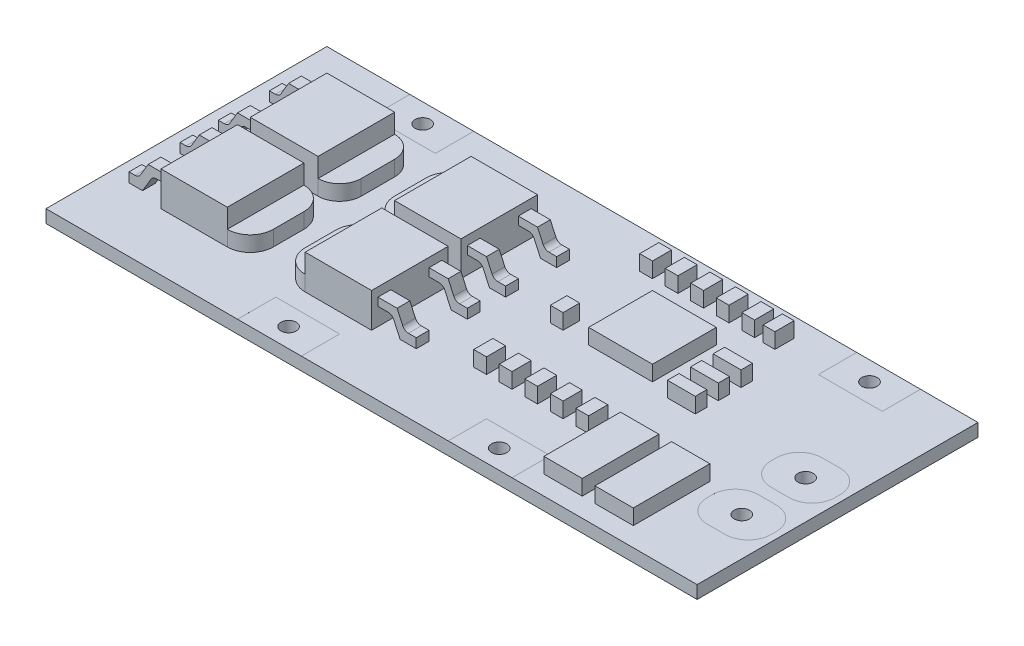
from build123d import *

# Parameters (mm, degrees)
SKETCH1_W                = 51
SKETCH1_H                = 22
SKETCH1_R                = 0.6
BOSS_EXTRUDE1_DEPTH      = 1
BOSS_EXTRUDE1_DEPTH_BACK = 0.01
SKETCH2_W                = 5
SKETCH2_H                = 3
CUT_EXTRUDE1_DEPTH       = 0.0001
SKETCH3_W                = 5
SKETCH3_H                = 3
CUT_EXTRUDE2_DEPTH       = 0.0001
SKETCH4_W                = 0.961538462
SKETCH4_H                = 0.256410257
BOSS_EXTRUDE2_DEPTH      = 0.0001
SKETCH5_W                = 3
SKETCH5_H                = 6
SKETCH5_W_2              = 5
SKETCH5_H_2              = 5
SKETCH5_W_3              = 1
SKETCH5_H_3              = 1.5
SKETCH5_W_4              = 0.919535101
SKETCH5_H_4              = 1.3
SKETCH5_W_5              = 2.183483736
SKETCH5_H_5              = 0.905155141
SKETCH5_H_6              = 0.884985371
SKETCH5_H_7              = 0.897685774
BOSS_EXTRUDE3_DEPTH      = 1.2
SKETCH6_W                = 5.2
SKETCH6_H                = 6
SKETCH6_W_2              = 5.307944278
BOSS_EXTRUDE4_DEPTH      = 1.5
SKETCH7_W                = 3
SKETCH7_H                = 1
BOSS_EXTRUDE5_DEPTH      = 2
CUT_EXTRUDE5_DEPTH       = 18


with BuildPart() as part:
    # Sketch1 → Boss-Extrude1 (new body, two sides)
    with BuildSketch(Plane(origin=(0, 0, 0), x_dir=(1, 0, 0), z_dir=(0, 1, 0))) as boss_extrude1_sk:
        Rectangle(SKETCH1_W, SKETCH1_H)
        with Locations((22.5, 0.5)):
            Circle(SKETCH1_R, mode=Mode.SUBTRACT)
        with Locations((22.5, -4.5)):
            Circle(SKETCH1_R, mode=Mode.SUBTRACT)
        with Locations((18.5, 9.5)):
            Circle(SKETCH1_R, mode=Mode.SUBTRACT)
        with Locations((-16.5, 9.5)):
            Circle(SKETCH1_R, mode=Mode.SUBTRACT)
        with Locations((8.5, -9.5)):
            Circle(SKETCH1_R, mode=Mode.SUBTRACT)
        with Locations((-8, -9.5)):
            Circle(SKETCH1_R, mode=Mode.SUBTRACT)
    extrude(amount=BOSS_EXTRUDE1_DEPTH)
    extrude(boss_extrude1_sk.sketch, amount=-BOSS_EXTRUDE1_DEPTH_BACK)

    # Sketch2 → Cut-Extrude1 (cut)
    with BuildSketch(Plane(origin=(0, 1, 0), x_dir=(1, 0, 0), z_dir=(0, 1, 0))):
        with Locations((-16.5, 9.5)):
            Rectangle(SKETCH2_W, SKETCH2_H)
        with Locations((18.5, 9.5)):
            Rectangle(SKETCH2_W, SKETCH2_H)
        with Locations((-8, -9.5)):
            Rectangle(SKETCH2_W, SKETCH2_H)
        with Locations((8.5, -9.5)):
            Rectangle(SKETCH2_W, SKETCH2_H)
        with BuildLine():
            Line((21.8, 2.5), (23.2, 2.5))
            ThreePointArc((23.2, 2.5), (24.472792206, 1.972792206), (25, 0.7))
            Line((25, 0.7), (25, 0.3))
            ThreePointArc((25, 0.3), (24.472792206, -0.972792206), (23.2, -1.5))
            Line((23.2, -1.5), (21.8, -1.5))
            ThreePointArc((21.8, -1.5), (20.527207794, -0.972792206), (20, 0.3))
            Line((20, 0.3), (20, 0.7))
            ThreePointArc((20, 0.7), (20.527207794, 1.972792206), (21.8, 2.5))
        make_face()
        with BuildLine():
            Line((21.8, -2.5), (23.2, -2.5))
            ThreePointArc((23.2, -2.5), (24.472792206, -3.027207794), (25, -4.3))
            Line((25, -4.3), (25, -4.7))
            ThreePointArc((25, -4.7), (24.472792206, -5.972792206), (23.2, -6.5))
            Line((23.2, -6.5), (21.8, -6.5))
            ThreePointArc((21.8, -6.5), (20.527207794, -5.972792206), (20, -4.7))
            Line((20, -4.7), (20, -4.3))
            ThreePointArc((20, -4.3), (20.527207794, -3.027207794), (21.8, -2.5))
        make_face()
    extrude(amount=-CUT_EXTRUDE1_DEPTH, mode=Mode.SUBTRACT)

    # Sketch3 → Cut-Extrude2 (cut)
    with BuildSketch(Plane.XZ.offset(0.01)):
        with Locations((18.5, -9.5)):
            Rectangle(SKETCH3_W, SKETCH3_H)
        with Locations((-16.5, -9.5)):
            Rectangle(SKETCH3_W, SKETCH3_H)
        with Locations((-8, 9.5)):
            Rectangle(SKETCH3_W, SKETCH3_H)
        with Locations((8.5, 9.5)):
            Rectangle(SKETCH3_W, SKETCH3_H)
        with BuildLine():
            Line((23.2, 2.5), (21.8, 2.5))
            ThreePointArc((21.8, 2.5), (20.527207794, 3.027207794), (20, 4.3))
            Line((20, 4.3), (20, 4.7))
            ThreePointArc((20, 4.7), (20.527207794, 5.972792206), (21.8, 6.5))
            Line((21.8, 6.5), (23.2, 6.5))
            ThreePointArc((23.2, 6.5), (24.472792206, 5.972792206), (25, 4.7))
            Line((25, 4.7), (25, 4.3))
            ThreePointArc((25, 4.3), (24.472792206, 3.027207794), (23.2, 2.5))
        make_face()
        with BuildLine():
            Line((23.2, -2.5), (21.8, -2.5))
            ThreePointArc((21.8, -2.5), (20.527207794, -1.972792206), (20, -0.7))
            Line((20, -0.7), (20, -0.3))
            ThreePointArc((20, -0.3), (20.527207794, 0.972792206), (21.8, 1.5))
            Line((21.8, 1.5), (23.2, 1.5))
            ThreePointArc((23.2, 1.5), (24.472792206, 0.972792206), (25, -0.3))
            Line((25, -0.3), (25, -0.7))
            ThreePointArc((25, -0.7), (24.472792206, -1.972792206), (23.2, -2.5))
        make_face()
    extrude(amount=-CUT_EXTRUDE2_DEPTH, mode=Mode.SUBTRACT)

    # Sketch4 → Boss-Extrude2 (add)
    with BuildSketch(Plane.XZ.offset(0.01)):
        Polygon((7.251426229, 1.791905181), (6.992511966, 1.791905181), (6.33796469, 0.769268963), (5.683417415, 1.791905181), (5.424503152, 1.791905181), (6.208257158, 0.566945245), (5.39245187, -0.708094819), (5.651366133, -0.708094819), (6.33796469, 0.364621527), (7.024563248, -0.708094819), (7.283477511, -0.708094819), (6.467171421, 0.566945245), align=None)
        Polygon((4.959759562, 1.791905181), (4.735400588, 1.791905181), (4.735400588, 0.766264155), (3.453349306, 0.766264155), (3.453349306, 1.791905181), (3.228990331, 1.791905181), (3.228990331, -0.708094819), (3.453349306, -0.708094819), (3.453349306, 0.509853899), (4.735400588, 0.509853899), (4.735400588, -0.708094819), (4.959759562, -0.708094819), align=None)
        with Locations((2.331554434, 0.253443643)):
            Rectangle(SKETCH4_W, SKETCH4_H)
        with BuildLine():
            Line((1.33796469, 1.214982104), (1.562323665, 1.214982104))
            add(Edge.make_bspline(
                [(1.562323665, 1.214982104), (1.556245414, 1.240148164), (1.544362932, 1.289345753), (1.519578951, 1.359636654), (1.492579483, 1.426153455), (1.460158694, 1.48765065), (1.424795298, 1.545364152), (1.384279068, 1.597984955), (1.340479266, 1.646851359), (1.292032874, 1.690217957), (1.241226687, 1.729487764), (1.187344816, 1.762969948), (1.13147132, 1.791772914), (1.073219082, 1.815501651), (1.012414674, 1.833377025), (0.9496078, 1.846346172), (0.884633872, 1.854768396), (0.84052845, 1.85559037), (0.81813296, 1.856007745)],
                knots=[0, 0, 0, 0, 7.7618e-05, 0.000151736, 0.000223351, 0.000292789, 0.000360048, 0.000426155, 0.000491745, 0.000556627, 0.000620933, 0.000684157, 0.000746647, 0.000809327, 0.000872549, 0.000936489, 0.001001588, 0.001068742, 0.001068742, 0.001068742, 0.001068742], degree=3))
            add(Edge.make_bspline(
                [(0.81813296, 1.856007745), (0.78550243, 1.855022581), (0.720953136, 1.853073741), (0.626122388, 1.835277715), (0.53467466, 1.807116906), (0.447610912, 1.768207101), (0.366740603, 1.720216163), (0.294786184, 1.663098494), (0.232722962, 1.597956136), (0.180655549, 1.526004304), (0.139887693, 1.449107512), (0.109825997, 1.369964542), (0.091524797, 1.288763134), (0.08915297, 1.233936506), (0.08796469, 1.206468482)],
                knots=[0, 0, 0, 0, 9.7812e-05, 0.000193489, 0.000288374, 0.000384325, 0.000478887, 0.000569769, 0.000659033, 0.00074799, 0.000835365, 0.000919359, 0.001001382, 0.001083733, 0.001083733, 0.001083733, 0.001083733], degree=3))
            add(Edge.make_bspline(
                [(0.08796469, 1.206468482), (0.088795827, 1.180035058), (0.090422232, 1.128308947), (0.104232022, 1.052793592), (0.127472209, 0.98162102), (0.159664897, 0.914491619), (0.201337433, 0.851831019), (0.251817931, 0.79349824), (0.311462689, 0.739234556), (0.35666193, 0.708149218), (0.379931838, 0.692145566)],
                knots=[0, 0, 0, 0, 7.9255e-05, 0.000155089, 0.000229365, 0.000303282, 0.000377732, 0.000454431, 0.000534203, 0.000618852, 0.000618852, 0.000618852, 0.000618852], degree=3))
            add(Edge.make_bspline(
                [(0.379931838, 0.692145566), (0.353337727, 0.679304015), (0.300647103, 0.653861188), (0.228825296, 0.603964218), (0.163626814, 0.546352541), (0.127267014, 0.501393504), (0.108998344, 0.47880422)],
                knots=[0, 0, 0, 0, 8.8473e-05, 0.000175291, 0.000261465, 0.000348485, 0.000348485, 0.000348485, 0.000348485], degree=3))
            add(Edge.make_bspline(
                [(0.108998344, 0.47880422), (0.096968814, 0.462334397), (0.073106745, 0.429664457), (0.043652793, 0.377138438), (0.016931997, 0.324030231), (-0.003889589, 0.26891637), (-0.020013779, 0.212435646), (-0.031539516, 0.154491077), (-0.038699617, 0.095035347), (-0.039725011, 0.054812147), (-0.040240438, 0.034593482)],
                knots=[0, 0, 0, 0, 6.1131e-05, 0.00012126, 0.000180389, 0.000239356, 0.00029769, 0.000356423, 0.000416429, 0.000477078, 0.000477078, 0.000477078, 0.000477078], degree=3))
            add(Edge.make_bspline(
                [(-0.040240438, 0.034593482), (-0.038958643, -0.000413461), (-0.036401084, -0.070262606), (-0.013541031, -0.173458835), (0.021896998, -0.274334194), (0.072223381, -0.370816222), (0.133557316, -0.461087923), (0.206526833, -0.541856715), (0.290302839, -0.61128429), (0.383735446, -0.669291595), (0.484961966, -0.71566154), (0.593230246, -0.747845427), (0.706980284, -0.768806856), (0.784985497, -0.771054619), (0.824643376, -0.772197383)],
                knots=[0, 0, 0, 0, 0.000104902, 0.00020931, 0.000315595, 0.000424898, 0.000534775, 0.000642204, 0.000750312, 0.000860092, 0.000971252, 0.001083258, 0.001198198, 0.001317066, 0.001317066, 0.001317066, 0.001317066], degree=3))
            add(Edge.make_bspline(
                [(0.824643376, -0.772197383), (0.851371448, -0.771577231), (0.90396338, -0.770356978), (0.981280165, -0.76201512), (1.055081378, -0.746779402), (1.125466805, -0.726277041), (1.192498974, -0.700282939), (1.255973335, -0.667912441), (1.316280402, -0.629832796), (1.372851081, -0.585594519), (1.42567863, -0.536107848), (1.473359147, -0.48049427), (1.516687571, -0.419781838), (1.554503741, -0.353265369), (1.588530136, -0.281804471), (1.616516533, -0.204484115), (1.641149082, -0.121995528), (1.652601557, -0.064511428), (1.658477511, -0.035017896)],
                knots=[0, 0, 0, 0, 8.0185e-05, 0.000157776, 0.000232912, 0.000305969, 0.000377485, 0.000448259, 0.000519394, 0.000591121, 0.000663393, 0.000736181, 0.000810525, 0.000886804, 0.000965437, 0.001047673, 0.00113325, 0.001223422, 0.001223422, 0.001223422, 0.001223422], degree=3))
            Line((1.658477511, -0.035017896), (1.434118536, -0.035017896))
            add(Edge.make_bspline(
                [(1.434118536, -0.035017896), (1.428273328, -0.054267191), (1.416903891, -0.091708742), (1.397550821, -0.145594675), (1.375502055, -0.194993284), (1.351848799, -0.240266943), (1.327007052, -0.281861516), (1.299210676, -0.318677137), (1.27051843, -0.352330853), (1.24889032, -0.37129129), (1.238305235, -0.38057078)],
                knots=[0, 0, 0, 0, 6.0348e-05, 0.000117382, 0.000171638, 0.000222486, 0.000270584, 0.000316758, 0.00036076, 0.000402938, 0.000402938, 0.000402938, 0.000402938], degree=3))
            add(Edge.make_bspline(
                [(1.238305235, -0.38057078), (1.224307681, -0.391362448), (1.196355778, -0.41291247), (1.150807042, -0.440413634), (1.102903552, -0.464242937), (1.051607356, -0.482445577), (0.998025377, -0.497858192), (0.941291545, -0.507944277), (0.88190639, -0.514864399), (0.841357987, -0.515475065), (0.820636966, -0.515787127)],
                knots=[0, 0, 0, 0, 5.2986e-05, 0.000105808, 0.000159337, 0.000213205, 0.000268857, 0.000326417, 0.000385869, 0.000448001, 0.000448001, 0.000448001, 0.000448001], degree=3))
            add(Edge.make_bspline(
                [(0.820636966, -0.515787127), (0.797241607, -0.515347194), (0.751494002, -0.514486945), (0.684740531, -0.506575725), (0.621235211, -0.495054002), (0.561683122, -0.477259014), (0.505304188, -0.455272691), (0.452888724, -0.427666688), (0.403748648, -0.395277601), (0.358513358, -0.358463916), (0.317837996, -0.318162848), (0.282024058, -0.276010654), (0.251577871, -0.232185062), (0.227018172, -0.186443547), (0.207624922, -0.138975526), (0.194422636, -0.089647791), (0.185242982, -0.038864029), (0.184495402, -0.004343337), (0.184118536, 0.013059027)],
                knots=[0, 0, 0, 0, 7.0157e-05, 0.000137186, 0.000201421, 0.000263541, 0.000323338, 0.000382699, 0.000440898, 0.000499637, 0.000557359, 0.000612441, 0.000665367, 0.000717127, 0.000767903, 0.00081881, 0.000870103, 0.000922246, 0.000922246, 0.000922246, 0.000922246], degree=3))
            add(Edge.make_bspline(
                [(0.184118536, 0.013059027), (0.185211609, 0.036352841), (0.187392315, 0.082824561), (0.2040413, 0.151194257), (0.231426203, 0.217068123), (0.269763711, 0.279322259), (0.316432089, 0.337019331), (0.370978451, 0.388498961), (0.433855757, 0.430977598), (0.491727092, 0.460326638), (0.542987918, 0.48035312), (0.58685605, 0.493692381), (0.635967909, 0.504987849), (0.689729587, 0.515496614), (0.74854617, 0.524440435), (0.812353626, 0.531898874), (0.881164884, 0.537866761), (0.928801431, 0.540531829), (0.953349306, 0.541905181)],
                knots=[0, 0, 0, 0, 6.9829e-05, 0.000139311, 0.000209808, 0.000283071, 0.000357843, 0.000431895, 0.000507184, 0.000584677, 0.000626062, 0.000672161, 0.000722085, 0.000777185, 0.000836468, 0.000900512, 0.000969883, 0.001043639, 0.001043639, 0.001043639, 0.001043639], degree=3))
            Line((0.953349306, 0.541905181), (0.953349306, 0.798315437))
            add(Edge.make_bspline(
                [(0.953349306, 0.798315437), (0.922419902, 0.798840297), (0.861836797, 0.799868369), (0.773340865, 0.812302662), (0.688717071, 0.82950311), (0.609840826, 0.855849676), (0.537948888, 0.886449888), (0.475577744, 0.922058609), (0.42360121, 0.961640573), (0.382271873, 1.005806723), (0.351179567, 1.053174614), (0.32844614, 1.102543655), (0.315017336, 1.154346556), (0.313224717, 1.18969989), (0.312323665, 1.207470085)],
                knots=[0, 0, 0, 0, 9.2715e-05, 0.000181605, 0.00026765, 0.000351427, 0.000430601, 0.000501726, 0.000566337, 0.000625867, 0.00068226, 0.000735602, 0.000788317, 0.000841593, 0.000841593, 0.000841593, 0.000841593], degree=3))
            add(Edge.make_bspline(
                [(0.312323665, 1.207470085), (0.312619673, 1.220525617), (0.313208566, 1.246498979), (0.320635193, 1.284445457), (0.331795222, 1.321231847), (0.347137886, 1.356701711), (0.367673742, 1.39060905), (0.392249447, 1.423242942), (0.421512376, 1.45441707), (0.455044838, 1.483474441), (0.49105327, 1.511166753), (0.530517395, 1.534676494), (0.572247306, 1.55478011), (0.616289202, 1.571358325), (0.662786009, 1.583829246), (0.711519265, 1.592783418), (0.762581896, 1.598381743), (0.797418847, 1.599187754), (0.815128152, 1.599597489)],
                knots=[0, 0, 0, 0, 3.9114e-05, 7.7815e-05, 0.000115518, 0.000154317, 0.000193395, 0.000234161, 0.000276679, 0.000321388, 0.000367161, 0.000412767, 0.000458909, 0.000505976, 0.000553721, 0.000603128, 0.000654505, 0.000707628, 0.000707628, 0.000707628, 0.000707628], degree=3))
            add(Edge.make_bspline(
                [(0.815128152, 1.599597489), (0.843593629, 1.598603659), (0.899193326, 1.596662478), (0.979346839, 1.579660325), (1.053860649, 1.552533123), (1.110816839, 1.520152394), (1.15287582, 1.488187799), (1.182930776, 1.460271809), (1.212445427, 1.429248363), (1.239478053, 1.393206666), (1.266816608, 1.354587531), (1.29170558, 1.311427758), (1.315891075, 1.264853191), (1.330464324, 1.231927738), (1.33796469, 1.214982104)],
                knots=[0, 0, 0, 0, 8.5314e-05, 0.000166639, 0.000244596, 0.000322429, 0.000362093, 0.000402856, 0.000445374, 0.000490351, 0.000537861, 0.000587248, 0.00063966, 0.00069524, 0.00069524, 0.00069524, 0.00069524], degree=3))
        make_face()
        with BuildLine():
            Line((-0.23254813, -0.225823184), (-0.443886271, -0.09912046))
            add(Edge.make_bspline(
                [(-0.443886271, -0.09912046), (-0.463542155, -0.132023592), (-0.50120207, -0.195064723), (-0.564024469, -0.280249038), (-0.629119406, -0.352650579), (-0.69696893, -0.411848155), (-0.767158893, -0.458454503), (-0.840147502, -0.491456097), (-0.915688796, -0.512038937), (-0.967098668, -0.514538999), (-0.992764476, -0.515787127)],
                knots=[0, 0, 0, 0, 0.000114929, 0.0002202, 0.000316984, 0.00040645, 0.000489652, 0.000568774, 0.000645907, 0.000722806, 0.000722806, 0.000722806, 0.000722806], degree=3))
            add(Edge.make_bspline(
                [(-0.992764476, -0.515787127), (-1.014683662, -0.515176646), (-1.0581385, -0.513966368), (-1.122111531, -0.502337223), (-1.18424139, -0.484471417), (-1.24324756, -0.458885037), (-1.298315856, -0.427928976), (-1.346606352, -0.390538849), (-1.388353576, -0.348677274), (-1.422502944, -0.301975377), (-1.448702969, -0.251748843), (-1.46884016, -0.200194592), (-1.480015213, -0.146502757), (-1.481698608, -0.110352427), (-1.48254813, -0.092109242)],
                knots=[0, 0, 0, 0, 6.5699e-05, 0.000130248, 0.00019443, 0.000259268, 0.000322751, 0.000383454, 0.000441885, 0.000499581, 0.00055626, 0.000611417, 0.000665143, 0.000719877, 0.000719877, 0.000719877, 0.000719877], degree=3))
            add(Edge.make_bspline(
                [(-1.48254813, -0.092109242), (-1.481495051, -0.071294349), (-1.479354295, -0.028980714), (-1.461260381, 0.033447609), (-1.432796633, 0.095228016), (-1.406537602, 0.133443206), (-1.392904701, 0.153283386)],
                knots=[0, 0, 0, 0, 6.2343e-05, 0.000126735, 0.000193507, 0.000265603, 0.000265603, 0.000265603, 0.000265603], degree=3))
            add(Edge.make_bspline(
                [(-1.392904701, 0.153283386), (-1.381711405, 0.167602546), (-1.35821248, 0.197663831), (-1.317814257, 0.242410427), (-1.27040989, 0.288566441), (-1.217621636, 0.337894339), (-1.157526573, 0.388099908), (-1.09200692, 0.441577249), (-1.019389877, 0.496292661), (-0.968461666, 0.532987351), (-0.942183547, 0.551921207)],
                knots=[0, 0, 0, 0, 5.4514e-05, 0.000114445, 0.000180666, 0.000252962, 0.000331129, 0.000415521, 0.000506668, 0.000603835, 0.000603835, 0.000603835, 0.000603835], degree=3))
            add(Edge.make_bspline(
                [(-0.942183547, 0.551921207), (-0.915880692, 0.570655912), (-0.865591638, 0.606475242), (-0.795264079, 0.659635445), (-0.732375177, 0.708238209), (-0.677204451, 0.752741075), (-0.629776167, 0.793150078), (-0.589716588, 0.829077178), (-0.55804619, 0.861494007), (-0.540435061, 0.882523537), (-0.532528098, 0.891965277)],
                knots=[0, 0, 0, 0, 9.6874e-05, 0.000185215, 0.000264453, 0.000335314, 0.000397836, 0.000451365, 0.000496698, 0.000533635, 0.000533635, 0.000533635, 0.000533635], degree=3))
            add(Edge.make_bspline(
                [(-0.532528098, 0.891965277), (-0.52147628, 0.906680304), (-0.499741397, 0.935619378), (-0.471051393, 0.980851419), (-0.446666277, 1.027153751), (-0.427550325, 1.074650797), (-0.411453026, 1.122675747), (-0.400625932, 1.171855208), (-0.393846363, 1.221968507), (-0.393152087, 1.255692436), (-0.39280454, 1.272574252)],
                knots=[0, 0, 0, 0, 5.5193e-05, 0.000108544, 0.000160512, 0.000211941, 0.000261986, 0.000312286, 0.000362787, 0.000413408, 0.000413408, 0.000413408, 0.000413408], degree=3))
            add(Edge.make_bspline(
                [(-0.39280454, 1.272574252), (-0.393736833, 1.299024091), (-0.39558149, 1.351358422), (-0.411181859, 1.427809015), (-0.435805355, 1.500799313), (-0.470301703, 1.569606694), (-0.514771241, 1.632439538), (-0.566232651, 1.6900206), (-0.62752657, 1.73842673), (-0.694778444, 1.780721057), (-0.768390138, 1.81382529), (-0.845526498, 1.838797418), (-0.926310121, 1.852946888), (-0.981026645, 1.854977435), (-1.008790117, 1.856007745)],
                knots=[0, 0, 0, 0, 7.9285e-05, 0.000156875, 0.000233051, 0.000309872, 0.000386839, 0.000463411, 0.000540685, 0.000620313, 0.000701216, 0.00078215, 0.000863002, 0.000946286, 0.000946286, 0.000946286, 0.000946286], degree=3))
            add(Edge.make_bspline(
                [(-1.008790117, 1.856007745), (-1.038250189, 1.854991637), (-1.096836869, 1.852970922), (-1.18301488, 1.835401257), (-1.26598682, 1.806329348), (-1.332732009, 1.77333745), (-1.384969696, 1.740386438), (-1.424807362, 1.710372278), (-1.46517697, 1.675818629), (-1.506404152, 1.636633453), (-1.547790337, 1.592457203), (-1.589949946, 1.543592425), (-1.632981567, 1.490337742), (-1.660664324, 1.452320242), (-1.674855822, 1.432830662)],
                knots=[0, 0, 0, 0, 8.8313e-05, 0.000175626, 0.000262577, 0.000351492, 0.000398313, 0.000447692, 0.00050098, 0.000557657, 0.000618237, 0.000682498, 0.000751247, 0.000823563, 0.000823563, 0.000823563, 0.000823563], degree=3))
            Line((-1.674855822, 1.432830662), (-1.472031303, 1.279084668))
            add(Edge.make_bspline(
                [(-1.472031303, 1.279084668), (-1.459784209, 1.294862304), (-1.436199168, 1.325246342), (-1.400392392, 1.367797282), (-1.366643357, 1.406666196), (-1.333393072, 1.440427002), (-1.302397621, 1.470928525), (-1.272314019, 1.497042637), (-1.243575197, 1.519025206), (-1.207348832, 1.542484891), (-1.161836176, 1.565739537), (-1.104704364, 1.58541745), (-1.044999882, 1.597242494), (-1.00433586, 1.598805985), (-0.983750053, 1.599597489)],
                knots=[0, 0, 0, 0, 5.9912e-05, 0.000115377, 0.000166823, 0.000214281, 0.000257489, 0.000297251, 0.00033371, 0.000365937, 0.000426633, 0.0004865, 0.000546706, 0.000608435, 0.000608435, 0.000608435, 0.000608435], degree=3))
            add(Edge.make_bspline(
                [(-0.983750053, 1.599597489), (-0.957923966, 1.598731989), (-0.908120789, 1.597062954), (-0.837413478, 1.578834393), (-0.77377496, 1.550133064), (-0.719094556, 1.50990808), (-0.673568144, 1.462250228), (-0.640635673, 1.407408188), (-0.620814127, 1.346849329), (-0.618395356, 1.304605289), (-0.617163515, 1.283091078)],
                knots=[0, 0, 0, 0, 7.732e-05, 0.000149104, 0.00021745, 0.000285567, 0.000351467, 0.000413907, 0.00047599, 0.000540422, 0.000540422, 0.000540422, 0.000540422], degree=3))
            add(Edge.make_bspline(
                [(-0.617163515, 1.283091078), (-0.61744432, 1.269697165), (-0.618006388, 1.242887437), (-0.625845529, 1.203279279), (-0.635916479, 1.163771179), (-0.651875501, 1.124540763), (-0.673907861, 1.084901935), (-0.70284013, 1.044172122), (-0.73927821, 1.00199233), (-0.767190361, 0.974558492), (-0.781927137, 0.960074252)],
                knots=[0, 0, 0, 0, 4.0114e-05, 8.0294e-05, 0.000120747, 0.000162317, 0.000206922, 0.000256524, 0.00031193, 0.000373902, 0.000373902, 0.000373902, 0.000373902], degree=3))
            add(Edge.make_bspline(
                [(-0.781927137, 0.960074252), (-0.787399545, 0.955190662), (-0.800400736, 0.94358837), (-0.824169255, 0.924593884), (-0.855556968, 0.901163332), (-0.893744254, 0.872172392), (-0.939435227, 0.838542776), (-0.99263491, 0.800704482), (-1.05275029, 0.757429154), (-1.095408802, 0.727173768), (-1.117964797, 0.711176014)],
                knots=[0, 0, 0, 0, 2.2001e-05, 5.227e-05, 9.1232e-05, 0.00013951, 0.000196103, 0.000261422, 0.000335358, 0.000418317, 0.000418317, 0.000418317, 0.000418317], degree=3))
            add(Edge.make_bspline(
                [(-1.117964797, 0.711176014), (-1.145097592, 0.691432186), (-1.197636489, 0.653200999), (-1.272391904, 0.595761228), (-1.340173195, 0.53958425), (-1.401218341, 0.485028817), (-1.456130418, 0.43250875), (-1.504300219, 0.381392193), (-1.546218562, 0.332045355), (-1.591346575, 0.26877923), (-1.637459303, 0.191078455), (-1.67706038, 0.095879713), (-1.702030628, 0.000310913), (-1.705295996, -0.063922542), (-1.706907105, -0.095614851)],
                knots=[0, 0, 0, 0, 0.000100666, 0.000194926, 0.000282772, 0.000364703, 0.000440498, 0.000510646, 0.000575344, 0.000634551, 0.000743634, 0.000845566, 0.000943101, 0.001038091, 0.001038091, 0.001038091, 0.001038091], degree=3))
            add(Edge.make_bspline(
                [(-1.706907105, -0.095614851), (-1.70643772, -0.118027969), (-1.705508067, -0.162418957), (-1.6948217, -0.227601155), (-1.679164796, -0.290908919), (-1.655566772, -0.351559714), (-1.626764516, -0.410663116), (-1.590217196, -0.466668759), (-1.547854564, -0.520816186), (-1.499259018, -0.571661537), (-1.446083373, -0.618337391), (-1.389880734, -0.65985815), (-1.33055911, -0.694478381), (-1.268440313, -0.722728982), (-1.203510072, -0.744824352), (-1.135790227, -0.760833544), (-1.065169147, -0.770659052), (-1.017168803, -0.771678881), (-0.992764476, -0.772197383)],
                knots=[0, 0, 0, 0, 6.7175e-05, 0.000133045, 0.000197664, 0.000262492, 0.00032789, 0.00039457, 0.000462695, 0.000533896, 0.000605222, 0.000674738, 0.000743194, 0.000810877, 0.000879135, 0.000948616, 0.001019371, 0.00109255, 0.00109255, 0.00109255, 0.00109255], degree=3))
            add(Edge.make_bspline(
                [(-0.992764476, -0.772197383), (-0.973882088, -0.771832253), (-0.936355117, -0.771106592), (-0.880848344, -0.764691392), (-0.826462923, -0.755614889), (-0.773881293, -0.74120484), (-0.722425999, -0.723721284), (-0.672320832, -0.702193904), (-0.623541508, -0.676395903), (-0.575814663, -0.646899457), (-0.529261681, -0.612572496), (-0.484319204, -0.572591428), (-0.439512643, -0.528058924), (-0.396164502, -0.477765664), (-0.353397971, -0.422524177), (-0.31205625, -0.361817617), (-0.271283594, -0.29597665), (-0.245701117, -0.249644446), (-0.23254813, -0.225823184)],
                knots=[0, 0, 0, 0, 5.6626e-05, 0.000112539, 0.000167456, 0.000221878, 0.000275883, 0.000330397, 0.00038528, 0.000441284, 0.000498577, 0.00055855, 0.000621584, 0.000687964, 0.000757583, 0.000831066, 0.000908199, 0.000989822, 0.000989822, 0.000989822, 0.000989822], degree=3))
        make_face()
        with Locations((-2.476137874, 0.253443643)):
            Rectangle(SKETCH4_W, SKETCH4_H)
        with BuildLine():
            Line((-3.373573771, -0.708094819), (-3.373573771, 1.791905181))
            Line((-3.373573771, 1.791905181), (-3.878381464, 1.791905181))
            add(Edge.make_bspline(
                [(-3.878381464, 1.791905181), (-3.922287884, 1.79158906), (-4.007114859, 1.790978315), (-4.129695178, 1.787105892), (-4.243112152, 1.78025556), (-4.346992765, 1.770277327), (-4.441622202, 1.75802516), (-4.526735494, 1.742667728), (-4.602772739, 1.724533321), (-4.649536625, 1.709072285), (-4.671650694, 1.70176095)],
                knots=[0, 0, 0, 0, 0.000131719, 0.000254481, 0.000367879, 0.000472526, 0.000567506, 0.000654046, 0.000731904, 0.000801753, 0.000801753, 0.000801753, 0.000801753], degree=3))
            add(Edge.make_bspline(
                [(-4.671650694, 1.70176095), (-4.700575508, 1.690739018), (-4.757769217, 1.668945093), (-4.839202876, 1.62783345), (-4.915863849, 1.581252663), (-4.988163239, 1.529141332), (-5.054449543, 1.47002394), (-5.117312327, 1.406411736), (-5.174179986, 1.335991493), (-5.226257341, 1.260223645), (-5.273211383, 1.18000075), (-5.314025067, 1.095475673), (-5.347920777, 1.007077667), (-5.376058796, 0.915052561), (-5.398234837, 0.819198006), (-5.413364788, 0.719402387), (-5.423344067, 0.616060109), (-5.42434696, 0.545935492), (-5.424855822, 0.5103547)],
                knots=[0, 0, 0, 0, 9.2811e-05, 0.000183516, 0.000273184, 0.000361735, 0.000450446, 0.000539336, 0.000629753, 0.000721575, 0.00081494, 0.000908343, 0.001002834, 0.001098676, 0.001196834, 0.001297696, 0.001401299, 0.001508012, 0.001508012, 0.001508012, 0.001508012], degree=3))
            add(Edge.make_bspline(
                [(-5.424855822, 0.5103547), (-5.42440656, 0.479453816), (-5.423521241, 0.418560395), (-5.41557173, 0.328816898), (-5.404017216, 0.241735776), (-5.386128503, 0.157731704), (-5.364412422, 0.076068691), (-5.336580885, -0.002382912), (-5.304698388, -0.078342775), (-5.267519903, -0.15078383), (-5.226704628, -0.21941481), (-5.182903383, -0.284111616), (-5.136162886, -0.34395106), (-5.086037434, -0.399114354), (-5.03317478, -0.449518339), (-4.977228829, -0.495584064), (-4.918055222, -0.536410175), (-4.855918991, -0.573600966), (-4.78900747, -0.606044077), (-4.71605328, -0.633494084), (-4.636745296, -0.656241667), (-4.551278184, -0.675220878), (-4.459504271, -0.690276094), (-4.361333581, -0.700366374), (-4.256916946, -0.707189898), (-4.185217471, -0.707787322), (-4.148313355, -0.708094819)],
                knots=[0, 0, 0, 0, 9.2682e-05, 0.00018264, 0.000270108, 0.000356049, 0.000440118, 0.000523429, 0.000605562, 0.000687088, 0.000767479, 0.000844986, 0.000921325, 0.000995067, 0.001068392, 0.001140274, 0.001212236, 0.001283866, 0.001357332, 0.001434997, 0.001517409, 0.001604646, 0.001697516, 0.001796235, 0.001900605, 0.0020113, 0.0020113, 0.0020113, 0.0020113], degree=3))
            Line((-4.148313355, -0.708094819), (-3.373573771, -0.708094819))
        make_face()
        with BuildLine():
            Line((-3.597932746, -0.451684563), (-3.88489188, -0.451684563))
            add(Edge.make_bspline(
                [(-3.88489188, -0.451684563), (-3.926126431, -0.451507351), (-4.005435572, -0.451166508), (-4.119476999, -0.448175648), (-4.223676568, -0.44328855), (-4.318049075, -0.436449209), (-4.402541235, -0.427400198), (-4.477329628, -0.417310982), (-4.542169098, -0.404741374), (-4.58140441, -0.393347832), (-4.59953531, -0.3880828)],
                knots=[0, 0, 0, 0, 0.000123702, 0.000237924, 0.000342211, 0.000436623, 0.000521737, 0.000597093, 0.000662996, 0.000719613, 0.000719613, 0.000719613, 0.000719613], degree=3))
            add(Edge.make_bspline(
                [(-4.59953531, -0.3880828), (-4.622355568, -0.380045972), (-4.667451024, -0.364164277), (-4.732366085, -0.335194519), (-4.792906803, -0.300878755), (-4.850128249, -0.262734274), (-4.903218717, -0.219415701), (-4.952807372, -0.171864995), (-4.998794373, -0.119840155), (-5.040704593, -0.063405754), (-5.078210524, -0.002913043), (-5.110689974, 0.061043267), (-5.139155354, 0.127762417), (-5.161497205, 0.198268959), (-5.179008337, 0.271932572), (-5.191411686, 0.348758439), (-5.199136489, 0.428732211), (-5.200037523, 0.483126586), (-5.200496848, 0.510855502)],
                knots=[0, 0, 0, 0, 7.2566e-05, 0.000143399, 0.000212909, 0.000281108, 0.000349467, 0.000418181, 0.000487012, 0.000557525, 0.000628819, 0.000700267, 0.000772537, 0.000846182, 0.000921858, 0.000999496, 0.001079477, 0.001162648, 0.001162648, 0.001162648, 0.001162648], degree=3))
            add(Edge.make_bspline(
                [(-5.200496848, 0.510855502), (-5.200130214, 0.540093702), (-5.199409959, 0.597532405), (-5.19035688, 0.681811473), (-5.177127198, 0.76286908), (-5.157995993, 0.840710649), (-5.133616794, 0.915488043), (-5.10319205, 0.986787693), (-5.068430179, 1.055362599), (-5.027070653, 1.119630004), (-4.9817738, 1.180410796), (-4.931503886, 1.236092878), (-4.877059573, 1.286803093), (-4.819034681, 1.333331173), (-4.755793896, 1.373805228), (-4.688826974, 1.41001), (-4.617151494, 1.440735636), (-4.567285283, 1.457077681), (-4.541943162, 1.465382745)],
                knots=[0, 0, 0, 0, 8.7676e-05, 0.00017224, 0.000253995, 0.000333918, 0.000412469, 0.00048967, 0.000566272, 0.000642822, 0.000718644, 0.000793464, 0.000867517, 0.000941663, 0.001016257, 0.001092438, 0.001169836, 0.001249815, 0.001249815, 0.001249815, 0.001249815], degree=3))
            add(Edge.make_bspline(
                [(-4.541943162, 1.465382745), (-4.520978058, 1.471180194), (-4.476400493, 1.48350716), (-4.403658019, 1.496953854), (-4.321790055, 1.508814211), (-4.230433126, 1.518855668), (-4.129691369, 1.526060897), (-4.019487306, 1.531468979), (-3.899773303, 1.535116574), (-3.816785779, 1.53536565), (-3.773713996, 1.535494925)],
                knots=[0, 0, 0, 0, 6.5229e-05, 0.000138695, 0.000221701, 0.000313396, 0.000414337, 0.000524651, 0.000644394, 0.000773604, 0.000773604, 0.000773604, 0.000773604], degree=3))
            Line((-3.773713996, 1.535494925), (-3.597932746, 1.535494925))
            Line((-3.597932746, 1.535494925), (-3.597932746, -0.451684563))
        make_face(mode=Mode.SUBTRACT)
        with BuildLine():
            add(Edge.make_bspline(
                [(-5.713317361, 0.540903578), (-5.71355166, 0.580973141), (-5.714006788, 0.658808844), (-5.719069946, 0.772226446), (-5.727480905, 0.878626652), (-5.7390076, 0.978014556), (-5.753034728, 1.070415817), (-5.771760076, 1.1555835), (-5.793054935, 1.233911791), (-5.817735253, 1.305656111), (-5.845583674, 1.371783042), (-5.87589386, 1.433515329), (-5.909868714, 1.490759566), (-5.945566509, 1.544429416), (-5.984432274, 1.593646341), (-6.025359981, 1.639105386), (-6.069947036, 1.679755922), (-6.116677756, 1.716788995), (-6.165975231, 1.749252903), (-6.216434278, 1.777847717), (-6.268402211, 1.802276193), (-6.322020913, 1.821483647), (-6.376808454, 1.837348538), (-6.432956359, 1.848197786), (-6.490557333, 1.855024149), (-6.529436929, 1.855676769), (-6.549154701, 1.856007745)],
                knots=[0, 0, 0, 0, 0.000120202, 0.000233494, 0.000340503, 0.000440329, 0.000533614, 0.000620743, 0.000701782, 0.00077701, 0.000848163, 0.00091692, 0.000983142, 0.00104773, 0.001110145, 0.00117112, 0.001231017, 0.00129093, 0.001349822, 0.001407902, 0.001464811, 0.001521845, 0.001578597, 0.001635759, 0.00169322, 0.001752349, 0.001752349, 0.001752349, 0.001752349], degree=3))
            add(Edge.make_bspline(
                [(-6.549154701, 1.856007745), (-6.569037185, 1.855659306), (-6.608577192, 1.854966369), (-6.667034603, 1.84830641), (-6.724141518, 1.837255608), (-6.779654474, 1.821597769), (-6.834029465, 1.802172286), (-6.886841184, 1.777824345), (-6.938417671, 1.749482297), (-6.987939305, 1.716179527), (-7.035949745, 1.67904933), (-7.081269718, 1.637075995), (-7.123903351, 1.590683339), (-7.164385712, 1.540367722), (-7.201568281, 1.48516409), (-7.236977876, 1.426032583), (-7.268672187, 1.361939108), (-7.299196955, 1.293953059), (-7.325544803, 1.220193303), (-7.349306407, 1.141075617), (-7.36850567, 1.055665483), (-7.384498007, 0.964411023), (-7.396887219, 0.866977106), (-7.405910535, 0.763572595), (-7.410677024, 0.654129459), (-7.411574668, 0.579302424), (-7.41203531, 0.540903578)],
                knots=[0, 0, 0, 0, 5.9629e-05, 0.000118583, 0.000176236, 0.000233953, 0.000291458, 0.000349276, 0.00040823, 0.000467817, 0.000528123, 0.000590144, 0.000652872, 0.000717006, 0.00078368, 0.000852391, 0.000923612, 0.000998055, 0.00107584, 0.001158394, 0.001245741, 0.001338285, 0.001436244, 0.001540301, 0.001649591, 0.001764792, 0.001764792, 0.001764792, 0.001764792], degree=3))
            add(Edge.make_bspline(
                [(-7.41203531, 0.540903578), (-7.411569892, 0.502672216), (-7.410663045, 0.428179964), (-7.405963969, 0.319229268), (-7.396707804, 0.216373522), (-7.385129241, 0.119366049), (-7.369092838, 0.028610607), (-7.349374863, -0.056206856), (-7.327481775, -0.135452621), (-7.300456922, -0.208477487), (-7.270877843, -0.276300146), (-7.23869556, -0.339633823), (-7.204217113, -0.399038318), (-7.166653724, -0.454038137), (-7.126615571, -0.505022892), (-7.083245722, -0.551092623), (-7.037766733, -0.593357389), (-6.989615007, -0.630965694), (-6.939321042, -0.663883412), (-6.887921701, -0.693321876), (-6.834504999, -0.717059515), (-6.780281461, -0.737441688), (-6.724475486, -0.753013439), (-6.667156635, -0.763780479), (-6.608616467, -0.771331799), (-6.56904392, -0.771907856), (-6.549154701, -0.772197383)],
                knots=[0, 0, 0, 0, 0.000114701, 0.00022349, 0.000327048, 0.000424447, 0.000516498, 0.000603358, 0.000685631, 0.000762946, 0.000836729, 0.000907504, 0.00097596, 0.001042634, 0.00110716, 0.001170229, 0.001232249, 0.001293259, 0.001353263, 0.001412461, 0.001470735, 0.001528412, 0.001586129, 0.001644273, 0.001703285, 0.001762914, 0.001762914, 0.001762914, 0.001762914], degree=3))
            add(Edge.make_bspline(
                [(-6.549154701, -0.772197383), (-6.529437476, -0.771864272), (-6.490558959, -0.771207442), (-6.432950083, -0.76441192), (-6.377034052, -0.75348656), (-6.322534942, -0.738188986), (-6.269173146, -0.719464103), (-6.217675798, -0.695068614), (-6.16747031, -0.666972851), (-6.118690627, -0.634976121), (-6.072253369, -0.598317776), (-6.027897222, -0.557771856), (-5.986736495, -0.512326562), (-5.948426426, -0.462699474), (-5.912016363, -0.409347158), (-5.878523954, -0.351541177), (-5.847544772, -0.289510741), (-5.819227993, -0.222855091), (-5.794121805, -0.150601571), (-5.771944871, -0.071923586), (-5.754434758, 0.013873297), (-5.739446933, 0.106099988), (-5.727358088, 0.205152795), (-5.719104998, 0.311085494), (-5.714004059, 0.423832071), (-5.713550437, 0.501167625), (-5.713317361, 0.540903578)],
                knots=[0, 0, 0, 0, 5.9128e-05, 0.00011659, 0.000173751, 0.000229886, 0.000286279, 0.000343188, 0.000400586, 0.000458784, 0.000517993, 0.000577891, 0.000638865, 0.000701676, 0.000765848, 0.000832502, 0.000901931, 0.00097374, 0.001049606, 0.001131261, 0.001218775, 0.00131214, 0.001411527, 0.001518038, 0.001630829, 0.001750029, 0.001750029, 0.001750029, 0.001750029], degree=3))
        make_face()
        with BuildLine():
            add(Edge.make_bspline(
                [(-5.937676335, 0.541905181), (-5.937761655, 0.508513253), (-5.937927243, 0.443706078), (-5.9422531, 0.349532321), (-5.948146123, 0.261696371), (-5.95574705, 0.180086703), (-5.96703487, 0.104979551), (-5.979682576, 0.035858349), (-5.995074068, -0.026911106), (-6.013284795, -0.083759543), (-6.034027007, -0.135651734), (-6.056674053, -0.183938317), (-6.081003141, -0.2291897), (-6.108231105, -0.27099942), (-6.137884722, -0.309503823), (-6.169294193, -0.345384418), (-6.203631753, -0.377382261), (-6.251134426, -0.415758586), (-6.313846194, -0.455415111), (-6.392860804, -0.489948032), (-6.474052555, -0.511649786), (-6.529160591, -0.514409612), (-6.55666672, -0.515787127)],
                knots=[0, 0, 0, 0, 0.000100165, 0.000194401, 0.000282747, 0.000364271, 0.000440195, 0.000510522, 0.000575018, 0.000633934, 0.000689453, 0.00074255, 0.000793869, 0.000843459, 0.000892039, 0.000939576, 0.000986341, 0.001032643, 0.001122675, 0.0012079, 0.001290617, 0.001373047, 0.001373047, 0.001373047, 0.001373047], degree=3))
            add(Edge.make_bspline(
                [(-6.55666672, -0.515787127), (-6.584350771, -0.514645855), (-6.639661716, -0.512365667), (-6.72047157, -0.490366569), (-6.798921763, -0.457174041), (-6.86040172, -0.417925822), (-6.907174966, -0.380548444), (-6.940687101, -0.348680838), (-6.971445707, -0.312998076), (-7.000618618, -0.274498579), (-7.027375101, -0.232446804), (-7.051705913, -0.187044965), (-7.073908304, -0.138166981), (-7.086557623, -0.104045739), (-7.093024893, -0.086600428)],
                knots=[0, 0, 0, 0, 8.2888e-05, 0.000165605, 0.000249513, 0.000337741, 0.000383339, 0.000429032, 0.000476238, 0.000524515, 0.000573834, 0.000625593, 0.000678935, 0.000734738, 0.000734738, 0.000734738, 0.000734738], degree=3))
            add(Edge.make_bspline(
                [(-7.093024893, -0.086600428), (-7.10056187, -0.064293471), (-7.115865166, -0.019000782), (-7.135587861, 0.051258969), (-7.15112029, 0.124975229), (-7.165094122, 0.201707455), (-7.174632019, 0.282021527), (-7.182309029, 0.365668944), (-7.186830948, 0.452712775), (-7.187391484, 0.511852054), (-7.187676335, 0.541905181)],
                knots=[0, 0, 0, 0, 7.0633e-05, 0.000143414, 0.000218756, 0.000296563, 0.000377314, 0.000461285, 0.000548541, 0.000638698, 0.000638698, 0.000638698, 0.000638698], degree=3))
            add(Edge.make_bspline(
                [(-7.187676335, 0.541905181), (-7.187283343, 0.571953447), (-7.186514566, 0.630734279), (-7.183576003, 0.716818694), (-7.175987736, 0.79858138), (-7.167559794, 0.876374575), (-7.155133207, 0.949767648), (-7.141734774, 1.019375009), (-7.123733908, 1.084334313), (-7.104505497, 1.145662585), (-7.082498072, 1.202663053), (-7.058272547, 1.255601472), (-7.032399863, 1.304733418), (-7.004298262, 1.34992409), (-6.974301346, 1.391375907), (-6.941617382, 1.42825776), (-6.90754283, 1.461712737), (-6.859816269, 1.499900287), (-6.797334633, 1.538837212), (-6.719587742, 1.574669898), (-6.638680139, 1.59524725), (-6.583984815, 1.598148455), (-6.55666672, 1.599597489)],
                knots=[0, 0, 0, 0, 9.0157e-05, 0.000176366, 0.000258297, 0.000336443, 0.000411035, 0.000481554, 0.000548977, 0.00061312, 0.000674316, 0.000732135, 0.000787694, 0.000840779, 0.000891664, 0.00094099, 0.000988447, 0.001034749, 0.001124091, 0.001208602, 0.001290711, 0.001372642, 0.001372642, 0.001372642, 0.001372642], degree=3))
            add(Edge.make_bspline(
                [(-6.55666672, 1.599597489), (-6.529016297, 1.598146455), (-6.473665079, 1.595241745), (-6.39191654, 1.574746564), (-6.313556288, 1.539023017), (-6.251239878, 1.499771322), (-6.20348003, 1.462386814), (-6.169849535, 1.429967919), (-6.138316555, 1.394506308), (-6.109268198, 1.355647798), (-6.082061567, 1.313886821), (-6.057075129, 1.268894846), (-6.034562751, 1.220443872), (-6.013788082, 1.168574989), (-5.995521805, 1.111731458), (-5.980454689, 1.049039319), (-5.966535365, 0.980137968), (-5.956681601, 0.904624034), (-5.947921776, 0.822993924), (-5.942292242, 0.734938697), (-5.937912772, 0.640606997), (-5.937756726, 0.575464741), (-5.937676335, 0.541905181)],
                knots=[0, 0, 0, 0, 8.2929e-05, 0.000166009, 0.000250977, 0.00034032, 0.000386309, 0.000432711, 0.000480247, 0.000528525, 0.000578114, 0.000629675, 0.000682772, 0.00073829, 0.000797207, 0.000861703, 0.000931633, 0.001007981, 0.001090055, 0.001177901, 0.001272637, 0.001373303, 0.001373303, 0.001373303, 0.001373303], degree=3))
        make_face(mode=Mode.SUBTRACT)
        Polygon((-8.167744444, 1.791905181), (-8.629984028, 1.791905181), (-8.629984028, -0.708094819), (-8.405625053, -0.708094819), (-8.405625053, 1.535494925), (-8.021009669, 1.535494925), align=None)
    extrude(amount=-BOSS_EXTRUDE2_DEPTH)

    # Sketch5 → Boss-Extrude3 (add)
    with BuildSketch(Plane(origin=(0, 1, 0), x_dir=(1, 0, 0), z_dir=(0, 1, 0))):
        with Locations((17.5, -6.5)):
            Rectangle(SKETCH5_W, SKETCH5_H)
        with Locations((13.5, -6.5)):
            Rectangle(SKETCH5_W, SKETCH5_H)
        with Locations((7.5, 3.5)):
            Rectangle(SKETCH5_W_2, SKETCH5_H_2)
        with BuildLine():
            Line((-4.5, -6.5), (-9.7, -6.5))
            ThreePointArc((-9.7, -6.5), (-10.972792206, -5.972792206), (-11.5, -4.7))
            Line((-11.5, -4.7), (-11.5, -2.3))
            ThreePointArc((-11.5, -2.3), (-10.972792206, -1.027207794), (-9.7, -0.5))
            Line((-9.7, -0.5), (-4.5, -0.5))
            Line((-4.5, -0.5), (-4.5, -6.5))
        make_face()
        with BuildLine():
            Line((-4.5, 0.5), (-9.7, 0.5))
            ThreePointArc((-9.7, 0.5), (-10.972792206, 1.027207794), (-11.5, 2.3))
            Line((-11.5, 2.3), (-11.5, 4.807944278))
            ThreePointArc((-11.5, 4.807944278), (-11.004408353, 6.004408353), (-9.807944278, 6.5))
            Line((-9.807944278, 6.5), (-4.5, 6.5))
            Line((-4.5, 6.5), (-4.5, 0.5))
        make_face()
        with BuildLine():
            Line((-15.8, -6.5), (-21, -6.5))
            Line((-21, -6.5), (-21, -0.5))
            Line((-21, -0.5), (-15.8, -0.5))
            ThreePointArc((-15.8, -0.5), (-14.527207794, -1.027207794), (-14, -2.3))
            Line((-14, -2.3), (-14, -4.7))
            ThreePointArc((-14, -4.7), (-14.527207794, -5.972792206), (-15.8, -6.5))
        make_face()
        with BuildLine():
            Line((-15.692055722, 0.5), (-21, 0.5))
            Line((-21, 0.5), (-21, 6.5))
            Line((-21, 6.5), (-15.692055722, 6.5))
            ThreePointArc((-15.692055722, 6.5), (-14.495591647, 6.004408353), (-14, 4.807944278))
            Line((-14, 4.807944278), (-14, 2.192055722))
            ThreePointArc((-14, 2.192055722), (-14.495591647, 0.995591647), (-15.692055722, 0.5))
        make_face()
        with Locations((10.5, -4.25)):
            Rectangle(SKETCH5_W_3, SKETCH5_H_3)
        with Locations((8.5, -4.25)):
            Rectangle(SKETCH5_W_3, SKETCH5_H_3)
        with Locations((6.5, -4.25)):
            Rectangle(SKETCH5_W_3, SKETCH5_H_3)
        with Locations((4.5, -4.25)):
            Rectangle(SKETCH5_W_3, SKETCH5_H_3)
        with Locations((2.5, -4.25)):
            Rectangle(SKETCH5_W_3, SKETCH5_H_3)
        with Locations((8.5, 8.75)):
            Rectangle(SKETCH5_W_3, SKETCH5_H_3)
        with Locations((6.5, 8.75)):
            Rectangle(SKETCH5_W_3, SKETCH5_H_3)
        with Locations((4.5, 8.75)):
            Rectangle(SKETCH5_W_3, SKETCH5_H_3)
        with Locations((2.5, 8.75)):
            Rectangle(SKETCH5_W_3, SKETCH5_H_3)
        with Locations((10.5, 8.75)):
            Rectangle(SKETCH5_W_3, SKETCH5_H_3)
        with Locations((12.133023748, 8.75)):
            Rectangle(SKETCH5_W_4, SKETCH5_H_3)
        with Locations((2.5, 1.65)):
            Rectangle(SKETCH5_W_3, SKETCH5_H_4)
        with Locations((12.764998065, 0.952577571)):
            Rectangle(SKETCH5_W_5, SKETCH5_H_5)
        with Locations((12.764998065, 2.742492686)):
            Rectangle(SKETCH5_W_5, SKETCH5_H_6)
        with Locations((12.764998065, 4.531514032)):
            Rectangle(SKETCH5_W_5, SKETCH5_H_7)
    extrude(amount=BOSS_EXTRUDE3_DEPTH)

    # Sketch6 → Boss-Extrude4 (add)
    with BuildSketch(Plane(origin=(0, 2.2, 0), x_dir=(1, 0, 0), z_dir=(0, 1, 0))):
        with Locations((-7.1, -3.5)):
            Rectangle(SKETCH6_W, SKETCH6_H)
        with Locations((-7.1, 3.5)):
            Rectangle(SKETCH6_W, SKETCH6_H)
        with Locations((-18.346027861, 3.5)):
            Rectangle(SKETCH6_W_2, SKETCH6_H)
        with Locations((-18.4, -3.5)):
            Rectangle(SKETCH6_W, SKETCH6_H)
    extrude(amount=BOSS_EXTRUDE4_DEPTH)

    # Sketch7 → Boss-Extrude5 (add)
    with BuildSketch(Plane(origin=(0, 1, 0), x_dir=(1, 0, 0), z_dir=(0, 1, 0))):
        with Locations((-3, -5.5)):
            Rectangle(SKETCH7_W, SKETCH7_H)
        with Locations((-3, -1.5)):
            Rectangle(SKETCH7_W, SKETCH7_H)
        with Locations((-3, 1.5)):
            Rectangle(SKETCH7_W, SKETCH7_H)
        with Locations((-3, 5.5)):
            Rectangle(SKETCH7_W, SKETCH7_H)
        with Locations((-22.5, -5.5)):
            Rectangle(SKETCH7_W, SKETCH7_H)
        with Locations((-22.5, -1.5)):
            Rectangle(SKETCH7_W, SKETCH7_H)
        with Locations((-22.5, 1.5)):
            Rectangle(SKETCH7_W, SKETCH7_H)
        with Locations((-22.5, 5.5)):
            Rectangle(SKETCH7_W, SKETCH7_H)
    extrude(amount=BOSS_EXTRUDE5_DEPTH)

    # Sketch8 → Cut-Extrude5 (cut, through all)
    with BuildSketch(Plane(origin=(0, 0, -6), x_dir=(-1, 0, 0), z_dir=(0, 0, -1))):
        with BuildLine():
            Line((3, 3), (2.562748323, 2.039768904))
            ThreePointArc((2.562748323, 2.039768904), (2.378255823, 1.826499266), (2.107704969, 1.746977846))
            Line((2.107704969, 1.746977846), (1.5, 1.746977846))
            Line((1.5, 1.746977846), (1.5, 3))
            Line((1.5, 3), (3, 3))
        make_face()
        with BuildLine():
            Line((22.5, 3), (23.102231352, 1.990765883))
            ThreePointArc((23.102231352, 1.990765883), (23.284723183, 1.812175602), (23.531597664, 1.746977846))
            Line((23.531597664, 1.746977846), (24, 1.746977846))
            Line((24, 1.746977846), (24, 3))
            Line((24, 3), (22.5, 3))
        make_face()
        with BuildLine():
            Line((4.5, 2.373488923), (3.711456633, 2.373488923))
            ThreePointArc((3.711456633, 2.373488923), (3.44090578, 2.293967502), (3.256413279, 2.080697865))
            Line((3.256413279, 2.080697865), (2.764305749, 1))
            Line((2.764305749, 1), (4.5, 1))
            Line((4.5, 1), (4.5, 2.373488923))
        make_face()
        with BuildLine():
            Line((21, 2.35), (21.849159333, 2.35))
            ThreePointArc((21.849159333, 2.35), (22.096033814, 2.284802243), (22.278525645, 2.106211963))
            Line((22.278525645, 2.106211963), (22.938625729, 1))
            Line((22.938625729, 1), (21, 1))
            Line((21, 1), (21, 2.35))
        make_face()
    extrude(amount=-CUT_EXTRUDE5_DEPTH, mode=Mode.SUBTRACT)


solid = part.part
